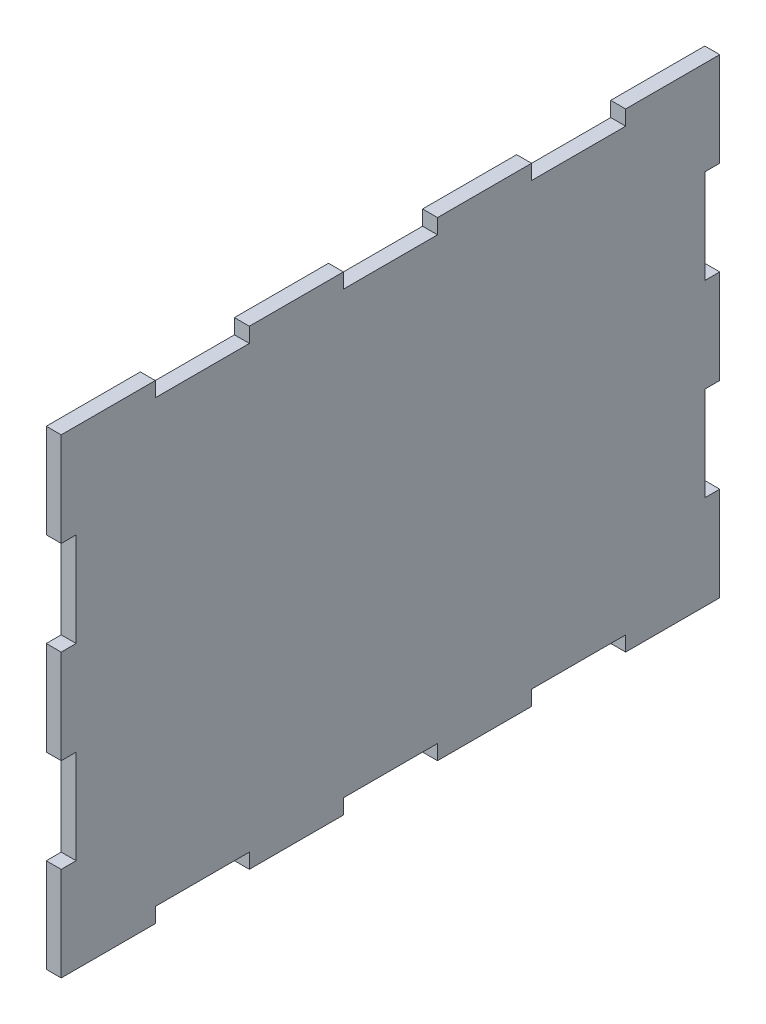
from build123d import *

# Parameters (mm, degrees)
SKETCH43_W           = 140
SKETCH43_H           = 99.999981374
BOSS_EXTRUDE10_DEPTH = 3.175
SKETCH45_W           = 3.175
SKETCH45_H           = 20
SKETCH45_W_2         = 20
SKETCH45_H_2         = 3.175
CUT_EXTRUDE22_DEPTH  = 3.175


with BuildPart() as part:
    # Sketch43 → Boss-Extrude10 (new body)
    with BuildSketch(Plane(origin=(0, 0, 0), x_dir=(0, 0, -1), z_dir=(1, 0, 0))):
        with Locations((-668.101928689, 4.4643e-05)):
            Rectangle(SKETCH43_W, SKETCH43_H)
    extrude(amount=BOSS_EXTRUDE10_DEPTH)

    # Sketch45 → Cut-Extrude22 (cut)
    with BuildSketch(Plane(origin=(3.175, 0, 0), x_dir=(0, 0, -1), z_dir=(1, 0, 0))):
        with Locations((-599.689428689, 20.000053956)):
            Rectangle(SKETCH45_W, SKETCH45_H)
        with Locations((-736.514428689, 20.000053956)):
            Rectangle(SKETCH45_W, SKETCH45_H)
        with Locations((-736.514428689, -19.999946044)):
            Rectangle(SKETCH45_W, SKETCH45_H)
        with Locations((-599.689428689, -19.999946044)):
            Rectangle(SKETCH45_W, SKETCH45_H)
        with Locations((-668.101928689, -48.412446044)):
            Rectangle(SKETCH45_W_2, SKETCH45_H_2)
        with Locations((-708.101928689, -48.412446044)):
            Rectangle(SKETCH45_W_2, SKETCH45_H_2)
        with Locations((-628.101928689, -48.412446044)):
            Rectangle(SKETCH45_W_2, SKETCH45_H_2)
        with Locations((-668.101928689, 48.41253533)):
            Rectangle(SKETCH45_W_2, SKETCH45_H_2)
        with Locations((-708.101928689, 48.41253533)):
            Rectangle(SKETCH45_W_2, SKETCH45_H_2)
        with Locations((-628.101928689, 48.41253533)):
            Rectangle(SKETCH45_W_2, SKETCH45_H_2)
    extrude(amount=-CUT_EXTRUDE22_DEPTH, mode=Mode.SUBTRACT)


solid = part.part
